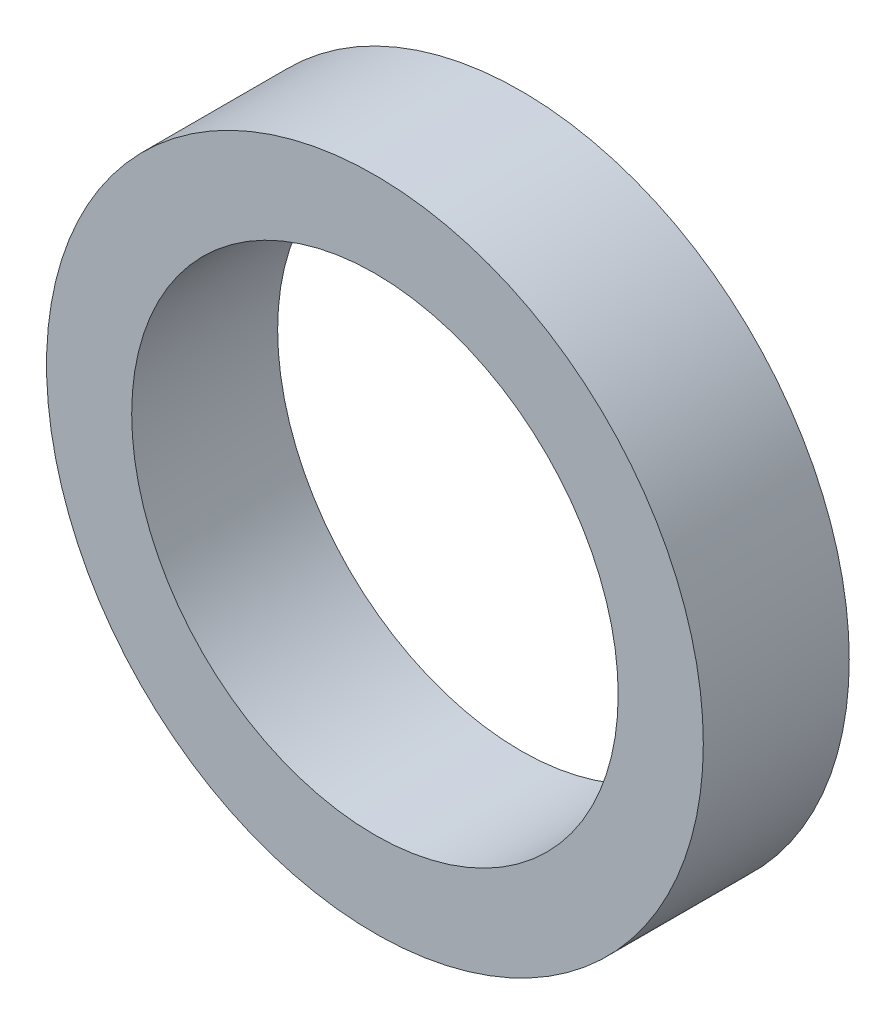
from build123d import *

# Parameters (mm, degrees)
SKETCH1_R           = 13.5
BOSS_EXTRUDE1_DEPTH = 6
SKETCH2_R           = 10
CUT_EXTRUDE1_DEPTH  = 7


with BuildPart() as part:
    # Sketch1 → Boss-Extrude1 (new body)
    with BuildSketch(Plane.XY):
        Circle(SKETCH1_R)
    extrude(amount=BOSS_EXTRUDE1_DEPTH)

    # Sketch2 → Cut-Extrude1 (cut, through all)
    with BuildSketch(Plane(origin=(0, 0, 0), x_dir=(-1, 0, 0), z_dir=(0, 0, -1))):
        Circle(SKETCH2_R)
    extrude(amount=-CUT_EXTRUDE1_DEPTH, mode=Mode.SUBTRACT)


solid = part.part
